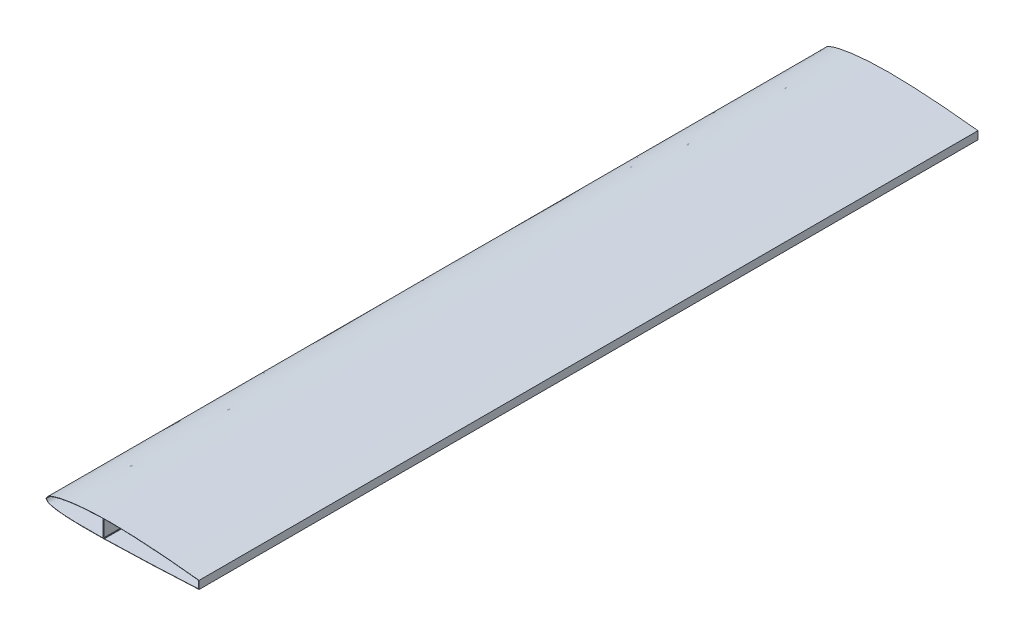
from build123d import *

# Parameters (mm, degrees)
SKIN_DEPTH          = 5500
SKETCH4_W           = 4
SKETCH4_H           = 122.034799648
SKETCH4_H_2         = 52.791225724
SPAR_DEPTH          = 5500
BOSS_EXTRUDE7_DEPTH = 5500


with BuildPart() as part:
    # Sketch3 → Skin (new body)
    with BuildSketch(Plane.XY):
        with BuildLine():
            Line((1078.8, 39.124924106), (1078.8, -17.023954163))
            add(Edge.make_bspline(
                [(1078.8, -17.023954163), (1033.412775607, -19.260197315), (942.6355193, -23.666574), (829.150643474, -28.94545361), (738.347536387, -32.892283297), (670.234387128, -35.647635484), (602.109293479, -38.141045599), (533.962961529, -40.201601635), (465.82130783, -41.973562795), (397.662710012, -43.470459074), (329.487580157, -44.423736758), (272.659023909, -44.522010937), (227.191727699, -43.940275994), (193.092925741, -43.081420909), (164.684496615, -41.911934709), (141.969518068, -40.609812963), (124.942671414, -39.415168689), (107.929533668, -37.959722654), (90.939962588, -36.179266993), (73.978174771, -33.999413656), (59.907309235, -31.704761736), (48.682169824, -29.524747965), (40.279017063, -27.622737038), (33.419281668, -25.705270663), (27.944060519, -24.058968044), (22.399253293, -22.379803031), (16.747408874, -20.394778522), (11.570423296, -17.306663498), (8.183456189, -14.392584993), (5.205791467, -11.089573319), (2.527185728, -7.516089354), (0.041347686, -3.789462727), (-1.54419507, -1.297478457), (-2.342250521, -0.050075072)],
                knots=[-0.000864693, -0.000864693, -0.000864693, -0.000864693, 0.099589756, 0.200044206, 0.250271431, 0.300498656, 0.350725881, 0.400953105, 0.45118033, 0.501407555, 0.55163478, 0.601862005, 0.626975617, 0.65208923, 0.677202842, 0.689759648, 0.702316454, 0.714873261, 0.727430067, 0.739986873, 0.752543679, 0.758822082, 0.765100485, 0.771378889, 0.77451809, 0.777657292, 0.783935695, 0.787074896, 0.790214098, 0.793353299, 0.796492501, 0.799631703, 0.802770904, 0.802770904, 0.802770904, 0.802770904], degree=3))
            add(Edge.make_bspline(
                [(-2.342250521, -0.050075072), (-1.599968387, 1.227315834), (-0.123881736, 3.779005631), (2.943694387, 8.879422439), (6.334851396, 13.76777967), (10.386173247, 18.101197693), (15.040381527, 21.908380347), (20.307378538, 24.749571485), (25.658230499, 27.188956358), (30.92690373, 29.530405764), (37.518766926, 32.364694049), (45.611878462, 35.437628279), (53.807450745, 38.203356503), (62.029313454, 40.787594263), (73.060160408, 44.004750807), (86.94816549, 47.637890351), (103.71292016, 51.527102133), (120.557367599, 55.018918002), (137.461547707, 58.173626598), (160.064659903, 61.984826814), (188.414986948, 66.09116239), (222.540353547, 70.148335165), (268.140252938, 74.555447502), (325.270225621, 78.412205941), (393.923917336, 80.874701392), (462.608496678, 81.484996061), (519.839885094, 80.626722231), (565.595034063, 79.235023547), (611.33745521, 77.524528655), (668.488468872, 74.777200717), (737.020206233, 70.627274282), (828.324192525, 64.056172987), (942.312765002, 54.070009934), (1033.334929592, 44.367483889), (1078.8, 39.124924106)],
                knots=[-0.000866031, -0.000866031, -0.000866031, -0.000866031, 0.002272396, 0.005410823, 0.011687676, 0.014826103, 0.017964529, 0.024241383, 0.027379809, 0.030518236, 0.036795089, 0.043071943, 0.049348796, 0.055625649, 0.061902503, 0.074456209, 0.087009916, 0.099563623, 0.112117329, 0.124671036, 0.149778449, 0.174885863, 0.199993276, 0.250208103, 0.30042293, 0.350637756, 0.400852583, 0.425959997, 0.45106741, 0.501282237, 0.551497063, 0.60171189, 0.702141544, 0.802571197, 0.802571197, 0.802571197, 0.802571197], degree=3))
        make_face()
        with BuildLine():
            Line((1076.8, 37.342290936), (1076.8, -15.120068714))
            add(Edge.make_bspline(
                [(0, 0), (3.939053907, -6.156952082), (10.625780654, -16.608663874), (27.103343175, -21.743890651), (40.641394629, -25.77523872), (54.34099345, -28.655504886), (67.94470855, -31.033690351), (81.555987306, -32.982802079), (95.157616186, -34.622194545), (108.758013409, -36.0090817), (122.356642884, -37.18961123), (135.954501639, -38.196103688), (149.551786564, -39.053686503), (163.148713377, -39.781987155), (176.745387974, -40.396841354), (190.341886078, -40.911247385), (203.938255983, -41.336068058), (217.534531315, -41.680512953), (231.130735509, -41.952491091), (244.726885407, -42.158870857), (258.322993309, -42.305676269), (271.919068357, -42.398237393), (285.515117453, -42.441307433), (299.111145877, -42.439155068), (312.70715772, -42.395638149), (326.30315619, -42.314263162), (339.899143826, -42.198233674), (353.495122659, -42.050490158), (367.091094324, -41.873743001), (380.687060154, -41.670500069), (394.283021238, -41.443089888), (407.878978474, -41.193681266), (421.474932606, -40.92429997), (435.070884259, -40.636843136), (448.666833945, -40.333091164), (462.262782129, -40.014719898), (475.858729079, -39.683304139), (489.45467549, -39.340347116), (503.050620205, -38.987207653), (516.64656876, -38.625404597), (530.242511984, -38.255509028), (543.83863451, -37.881300443), (557.434614286, -37.48747277), (571.030570097, -37.075412536), (584.626524548, -36.646064915), (598.222478107, -36.200430215), (611.81843086, -35.739433298), (625.414382973, -35.263961618), (639.010334568, -34.77485794), (652.606285764, -34.27292493), (666.202236662, -33.758926311), (679.798187355, -33.233588725), (693.394137925, -32.697603203), (706.990088445, -32.151626579), (720.586038981, -31.596282748), (734.181989591, -31.032163838), (747.777940328, -30.459831275), (761.373891237, -29.879816763), (774.96984236, -29.29262319), (788.565793733, -28.698725455), (802.161745389, -28.098571236), (815.757697355, -27.492581701), (829.353649656, -26.881152163), (842.949602314, -26.264652688), (856.545555348, -25.643428657), (870.141508774, -25.017801294), (883.737462606, -24.388068148), (897.333416856, -23.75450355), (910.929371533, -23.117359034), (924.525326646, -22.476863735), (938.121282203, -21.833224752), (951.717238209, -21.186627494), (965.313194669, -20.537236007), (978.909151586, -19.885193271), (992.505108963, -19.230621484), (1006.101066804, -18.573622331), (1019.697025111, -17.914277229), (1033.292983884, -17.252647566), (1046.888943126, -16.588774921), (1060.484902839, -15.922681269), (1070.45524148, -15.43258732), (1075.893603431, -15.164727164), (1076.8, -15.120068714)],
                knots=[0, 0, 0, 0, 0.015540209, 0.026380226, 0.036798074, 0.047052742, 0.057224274, 0.067347157, 0.0774391, 0.087510256, 0.097566912, 0.107613182, 0.117651878, 0.127684982, 0.137713931, 0.147739788, 0.157763352, 0.16778523, 0.177805891, 0.187825695, 0.197844926, 0.207863801, 0.217882492, 0.227901132, 0.237919821, 0.247938637, 0.257957638, 0.267976866, 0.277996347, 0.288016102, 0.298036138, 0.308056458, 0.318077059, 0.328097933, 0.338119068, 0.348140449, 0.35816206, 0.368183882, 0.378205895, 0.388228079, 0.398250413, 0.408272898, 0.418295735, 0.428318971, 0.4383426, 0.448366616, 0.458391009, 0.468415769, 0.478440886, 0.488466347, 0.498492139, 0.508518252, 0.51854467, 0.528571381, 0.538598371, 0.548625628, 0.558653137, 0.568680886, 0.578708863, 0.588737053, 0.598765446, 0.60879403, 0.618822793, 0.628851725, 0.638880815, 0.648910054, 0.658939433, 0.668968942, 0.678998575, 0.689028324, 0.699058183, 0.709088145, 0.719118205, 0.729148358, 0.739178601, 0.749208931, 0.759239344, 0.769269839, 0.779300414, 0.78933107, 0.799361805, 0.801367962, 0.801367962, 0.801367962, 0.801367962], degree=3))
            add(Edge.make_bspline(
                [(0, 0), (3.910137059, 6.728942126), (10.505848228, 18.079479985), (27.011245301, 25.648074919), (40.589975358, 31.571888436), (54.301081707, 36.319190946), (67.914982725, 40.492179672), (81.531937039, 44.185690612), (95.137870337, 47.515911112), (108.741361611, 50.542050252), (122.342396646, 53.310244351), (135.942156312, 55.853093735), (149.540989804, 58.195805909), (163.139202518, 60.35807996), (176.736964447, 62.355790866), (190.334395556, 64.201964663), (203.93157631, 65.907482638), (217.528564029, 67.481567488), (231.125400023, 68.932137631), (244.722114838, 70.266068373), (258.318731448, 71.48938891), (271.915267438, 72.607433256), (285.511736462, 73.624957665), (299.108149275, 74.546233207), (312.704514449, 75.375119633), (326.300838898, 76.115124953), (339.897128256, 76.769453969), (353.49338716, 77.341048166), (367.089619459, 77.832618766), (380.685828379, 78.246674329), (394.282016641, 78.585543966), (407.87818656, 78.851396965), (421.47434012, 79.046259546), (435.070479027, 79.172029061), (448.666604774, 79.230486727), (462.262718625, 79.223306736), (475.858821829, 79.152071246), (489.454914965, 79.018257057), (503.051000507, 78.82332253), (516.647073339, 78.56841578), (530.243145944, 78.255492764), (543.839015608, 77.883173168), (557.434997537, 77.46904059), (571.031000282, 77.013870078), (584.626999031, 76.518773569), (598.222994667, 75.984707089), (611.818987353, 75.412607398), (625.414977412, 74.803358785), (639.010965093, 74.157804888), (652.606950636, 73.476748157), (666.20293426, 72.760952388), (679.798916169, 72.011144215), (693.39489655, 71.228014682), (706.990875579, 70.412220626), (720.586853418, 69.564385947), (734.182830218, 68.685102777), (747.778806122, 67.774932541), (761.374781263, 66.834406944), (774.970755765, 65.864028873), (788.566729746, 64.864273224), (802.162703318, 63.835587673), (815.758676586, 62.778393385), (829.354649649, 61.693085667), (842.950622602, 60.580034579), (856.546595535, 59.439585498), (870.142568534, 58.27205964), (883.738541681, 57.077754546), (897.334515055, 55.856944542), (910.930488732, 54.609881152), (924.526462785, 53.336793502), (938.122437285, 52.037888681), (951.7184123, 50.713352091), (965.314387897, 49.363347765), (978.910364139, 47.988018674), (992.50634109, 46.587487004), (1006.102318812, 45.161854429), (1019.698297365, 43.711202354), (1033.294276808, 42.235592156), (1046.890257201, 40.735065399), (1060.486238601, 39.209644046), (1070.455800278, 38.072841685), (1075.893621574, 37.446805083), (1076.8, 37.342290936)],
                knots=[0, 0, 0, 0, 0.016572196, 0.02795437, 0.038760258, 0.049311955, 0.05971786, 0.070028271, 0.080270864, 0.090462616, 0.100614756, 0.110735144, 0.12082953, 0.130902263, 0.140956735, 0.150995648, 0.161021202, 0.171035219, 0.181039228, 0.191034529, 0.201022242, 0.211003338, 0.220978668, 0.230948983, 0.240914952, 0.250877171, 0.260836176, 0.270792452, 0.280746437, 0.290698533, 0.300649104, 0.310598486, 0.320546986, 0.330494889, 0.340442457, 0.350389934, 0.360337545, 0.370285501, 0.380233996, 0.390183215, 0.400133329, 0.410084475, 0.420036561, 0.429989605, 0.439943669, 0.449898812, 0.459855085, 0.469812538, 0.479771216, 0.489731159, 0.499692406, 0.509654993, 0.519618951, 0.529584313, 0.539551106, 0.549519358, 0.559489094, 0.569460338, 0.579433114, 0.589407442, 0.599383346, 0.609360845, 0.619339959, 0.62932071, 0.639303116, 0.649287198, 0.659272976, 0.669260469, 0.679249699, 0.689240686, 0.699233452, 0.709228019, 0.71922441, 0.729222649, 0.739222761, 0.749224772, 0.759228709, 0.769234599, 0.779242474, 0.789252363, 0.799264299, 0.801266935, 0.801266935, 0.801266935, 0.801266935], degree=3))
        make_face(mode=Mode.SUBTRACT)
    extrude(amount=SKIN_DEPTH)

    # Sketch4 → Spar (add)
    with BuildSketch(Plane.XY):
        with Locations((403.8, 18.7502358)):
            Rectangle(SKETCH4_W, SKETCH4_H)
        with Locations((1076.800000005, 11.177027746)):
            Rectangle(SKETCH4_W, SKETCH4_H_2)
    extrude(amount=SPAR_DEPTH)

    # Sketch5 → Boss-Extrude7 (add)
    with BuildSketch(Plane.XY):
        Polygon((401.8, 74.72979395), (399.8, 74.72979395), (399.8, 76.649450634), (397.8, 76.649450634), (397.8, 79.649450634), (401.8, 79.72979395), align=None)
        Polygon((405.8, 79.803931082), (405.8, 74.803931082), (407.80022926, 74.803931082), (407.80022926, 76.723587766), (409.80022926, 76.723587766), (409.80022926, 79.871908373), align=None)
        Polygon((401.8, -42.304291282), (397.8, -42.377176666), (397.8, -39.377176666), (399.8, -39.377176666), (399.8, -37.304291282), (401.8, -37.304291282), align=None)
        Polygon((405.8, -42.229589407), (405.8, -37.229589407), (407.8, -37.229589407), (407.8, -39.153126443), (409.799933211, -39.153126443), (409.799933211, -42.153126443), align=None)
        Polygon((1074.800000005, 38.578946967), (1070.800000005, 39.037564138), (1070.800000005, 36.037564138), (1072.800000005, 36.037564138), (1072.800000005, 33.578946967), (1074.800000005, 33.578946967), align=None)
        Polygon((1074.800000005, -16.219772776), (1070.778661727, -16.417682258), (1070.778661727, -13.417682258), (1072.800000005, -13.417682258), (1072.800000005, -11.219772776), (1074.800000005, -11.219772776), align=None)
    extrude(amount=BOSS_EXTRUDE7_DEPTH)


solid = part.part
